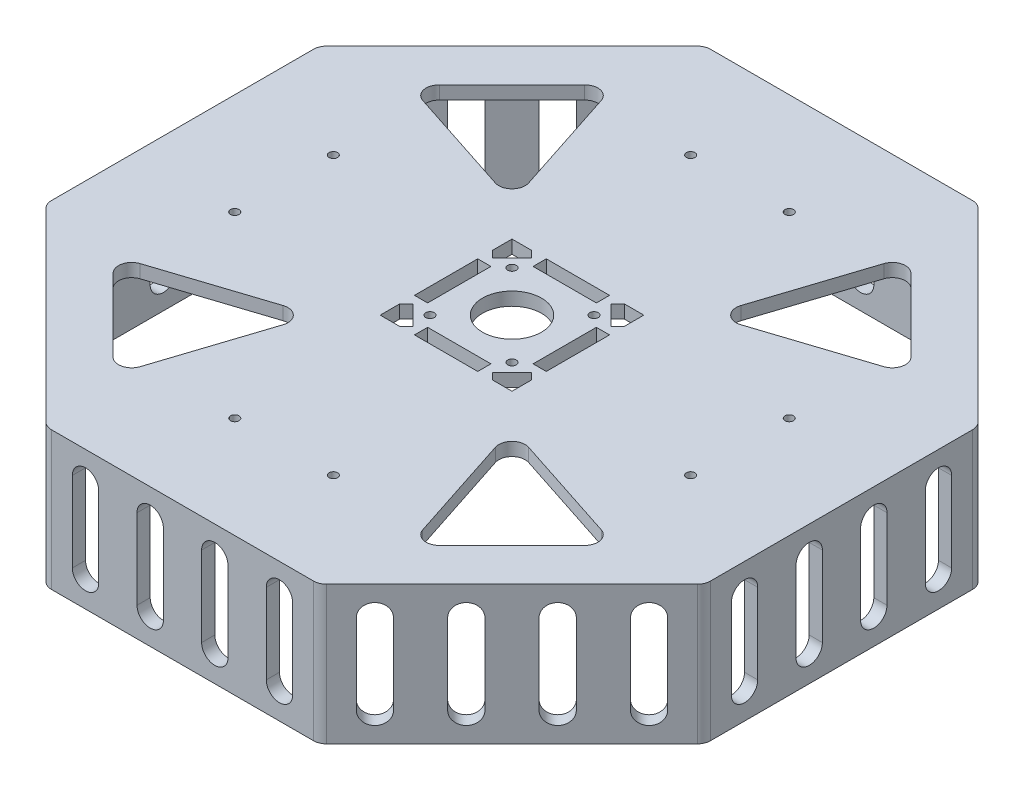
from build123d import *

# Parameters (mm, degrees)
SKETCH3_W           = 24
SKETCH3_H           = 5
SKETCH3_W_2         = 5
SKETCH3_H_2         = 24
SKETCH3_R           = 1.625
SKETCH3_R_2         = 11.2
BOSS_EXTRUDE3_DEPTH = 5
BOSS_EXTRUDE5_DEPTH = 47.48
CUT_EXTRUDE1_DEPTH  = 5
CIRPATTERN5_COUNT   = 8
FILLET2_R           = 5
CUT_EXTRUDE2_REACH  = 186.402
SKETCH7_R           = 1.625


with BuildPart() as part:
    # Sketch3 → Boss-Extrude3 (new body)
    with BuildSketch(Plane(origin=(0, 0, 0), x_dir=(1, 0, 0), z_dir=(0, 1, 0))):
        Polygon((51.776695297, 125), (-51.776695297, 125), (-125, 51.776695297), (-125, -51.776695297), (-51.776695297, -125), (51.776695297, -125), (125, -51.776695297), (125, 51.776695297), align=None)
        Polygon((-95.201010127, -56.119841047), (-37.207004987, -37.207004987), (-56.119841047, -95.201010127), align=None, mode=Mode.SUBTRACT)
        Polygon((56.119841047, -95.201010127), (37.207004987, -37.207004987), (95.201010127, -56.119841047), align=None, mode=Mode.SUBTRACT)
        Polygon((-17.646089476, -25), (-25, -25), (-25, -17.646089476), (-22.5, -15.146089476), (-15.146089476, -22.5), align=None, mode=Mode.SUBTRACT)
        with Locations((0, -22.5)):
            Rectangle(SKETCH3_W, SKETCH3_H, mode=Mode.SUBTRACT)
        Polygon((25, -25), (17.646089476, -25), (15.146089476, -22.5), (22.5, -15.146089476), (25, -17.646089476), align=None, mode=Mode.SUBTRACT)
        with Locations((22.5, 0)):
            Rectangle(SKETCH3_W_2, SKETCH3_H_2, mode=Mode.SUBTRACT)
        Polygon((25, 25), (25, 17.646089476), (22.5, 15.146089476), (15.146089476, 22.5), (17.646089476, 25), align=None, mode=Mode.SUBTRACT)
        with Locations((0, 22.5)):
            Rectangle(SKETCH3_W, SKETCH3_H, mode=Mode.SUBTRACT)
        Polygon((-25, 25), (-17.646089476, 25), (-15.146089476, 22.5), (-22.5, 15.146089476), (-25, 17.646089476), align=None, mode=Mode.SUBTRACT)
        with Locations((-22.5, 0)):
            Rectangle(SKETCH3_W_2, SKETCH3_H_2, mode=Mode.SUBTRACT)
        Polygon((-37.207004987, 37.207004987), (-95.201010127, 56.119841047), (-56.119841047, 95.201010127), align=None, mode=Mode.SUBTRACT)
        Polygon((95.201010127, 56.119841047), (37.207004987, 37.207004987), (56.119841047, 95.201010127), align=None, mode=Mode.SUBTRACT)
        with Locations((-15.55, -15.55)):
            Circle(SKETCH3_R, mode=Mode.SUBTRACT)
        with Locations((15.55, -15.55)):
            Circle(SKETCH3_R, mode=Mode.SUBTRACT)
        Circle(SKETCH3_R_2, mode=Mode.SUBTRACT)
        with Locations((-15.55, 15.55)):
            Circle(SKETCH3_R, mode=Mode.SUBTRACT)
        with Locations((15.55, 15.55)):
            Circle(SKETCH3_R, mode=Mode.SUBTRACT)
    extrude(amount=BOSS_EXTRUDE3_DEPTH)

    # Sketch5 → Boss-Extrude5 (add)
    with BuildSketch(Plane.XZ):
        Polygon((51.776695297, 125), (-51.776695297, 125), (-125, 51.776695297), (-125, -51.776695297), (-51.776695297, -125), (51.776695297, -125), (125, -51.776695297), (125, 51.776695297), align=None)
        Polygon((-49.705627485, 120), (-120, 49.705627485), (-120, -49.705627485), (-49.705627485, -120), (49.705627485, -120), (120, -49.705627485), (120, 49.705627485), (49.705627485, 120), align=None, mode=Mode.SUBTRACT)
    extrude(amount=BOSS_EXTRUDE5_DEPTH)

    # Sketch6 → Cut-Extrude1 (cut)
    with BuildSketch(Plane(origin=(-88.388347648, 0, 88.388347648), x_dir=(0.7071067811865478, 0, 0.7071067811865472), z_dir=(-0.7071067811865472, 0, 0.7071067811865478))):
        with BuildLine():
            Line((-31.776695297, -36.44), (-31.776695297, -6.04))
            ThreePointArc((-31.776695297, -6.04), (-36.776695297, -1.04), (-41.776695297, -6.04))
            Line((-41.776695297, -6.04), (-41.776695297, -36.44))
            ThreePointArc((-41.776695297, -36.44), (-36.776695297, -41.44), (-31.776695297, -36.44))
        make_face()
        with BuildLine():
            ThreePointArc((-7.258898432, -6.04), (-12.258898432, -1.04), (-17.258898432, -6.04))
            Line((-17.258898432, -6.04), (-17.258898432, -36.44))
            ThreePointArc((-17.258898432, -36.44), (-12.258898432, -41.44), (-7.258898432, -36.44))
            Line((-7.258898432, -36.44), (-7.258898432, -6.04))
        make_face()
        with BuildLine():
            ThreePointArc((17.258898432, -6.04), (12.258898432, -1.04), (7.258898432, -6.04))
            Line((7.258898432, -6.04), (7.258898432, -36.44))
            ThreePointArc((7.258898432, -36.44), (12.258898432, -41.44), (17.258898432, -36.44))
            Line((17.258898432, -36.44), (17.258898432, -6.04))
        make_face()
        with BuildLine():
            ThreePointArc((41.776695297, -6.04), (36.776695297, -1.04), (31.776695297, -6.04))
            Line((31.776695297, -6.04), (31.776695297, -36.44))
            ThreePointArc((31.776695297, -36.44), (36.776695297, -41.44), (41.776695297, -36.44))
            Line((41.776695297, -36.44), (41.776695297, -6.04))
        make_face()
    cut_extrude1 = extrude(amount=-CUT_EXTRUDE1_DEPTH, mode=Mode.SUBTRACT)

    # CirPattern5: Cut-Extrude1 ×8 about axis
    cirpattern5_axis = Axis((0, 5, 0), (0, 1, 0))
    for i in range(1, CIRPATTERN5_COUNT):
        add(cut_extrude1.rotate(cirpattern5_axis, i * 360 / CIRPATTERN5_COUNT), mode=Mode.SUBTRACT)

    # Fillet2
    fillet2_edges = [part.edges().sort_by_distance(p)[0] for p in [
        (-56.119841047, 2.5, 95.201010127),
        (-95.201010127, 2.5, 56.119841047),
        (-37.207004987, 2.5, 37.207004987),
        (56.119841047, 2.5, 95.201010127),
        (49.705627485, -23.74, 120),
        (95.201010127, 2.5, 56.119841047),
        (37.207004987, 2.5, 37.207004987),
        (37.207004987, 2.5, -37.207004987),
        (95.201010127, 2.5, -56.119841047),
        (56.119841047, 2.5, -95.201010127),
        (-95.201010127, 2.5, -56.119841047),
        (-37.207004987, 2.5, -37.207004987),
        (-56.119841047, 2.5, -95.201010127),
        (49.705627485, -23.74, -120),
        (51.776695297, -21.24, -125),
        (120, -23.74, 49.705627485),
        (120, -23.74, -49.705627485),
        (125, -21.24, -51.776695297),
        (125, -21.24, 51.776695297),
        (51.776695297, -21.24, 125),
        (-51.776695297, -21.24, 125),
        (-49.705627485, -23.74, 120),
        (-125, -21.24, 51.776695297),
        (-120, -23.74, 49.705627485),
        (-49.705627485, -23.74, -120),
        (-120, -23.74, -49.705627485),
        (-125, -21.24, -51.776695297),
        (-51.776695297, -21.24, -125),
    ]]
    fillet(fillet2_edges, radius=FILLET2_R)

    # Sketch7 → Cut-Extrude2 (cut, up to next)
    with BuildSketch(Plane(origin=(0, 5, 0), x_dir=(1, 0, 0), z_dir=(0, 1, 0)), mode=Mode.PRIVATE) as cut_extrude2_sk1:
        with Locations((-86.475, 18.7)):
            Circle(SKETCH7_R)
    cut_extrude2_tool1 = extrude(cut_extrude2_sk1.sketch, amount=-CUT_EXTRUDE2_REACH, mode=Mode.PRIVATE) & part.part
    # Sketch7 → Cut-Extrude2 (cut, up to next)
    with BuildSketch(Plane(origin=(0, 5, 0), x_dir=(1, 0, 0), z_dir=(0, 1, 0)), mode=Mode.PRIVATE) as cut_extrude2_sk2:
        with Locations((-86.475, -18.7)):
            Circle(SKETCH7_R)
    cut_extrude2_tool2 = extrude(cut_extrude2_sk2.sketch, amount=-CUT_EXTRUDE2_REACH, mode=Mode.PRIVATE) & part.part
    # Sketch7 → Cut-Extrude2 (cut, up to next)
    with BuildSketch(Plane(origin=(0, 5, 0), x_dir=(1, 0, 0), z_dir=(0, 1, 0)), mode=Mode.PRIVATE) as cut_extrude2_sk3:
        with Locations((18.7, 86.475)):
            Circle(SKETCH7_R)
    cut_extrude2_tool3 = extrude(cut_extrude2_sk3.sketch, amount=-CUT_EXTRUDE2_REACH, mode=Mode.PRIVATE) & part.part
    # Sketch7 → Cut-Extrude2 (cut, up to next)
    with BuildSketch(Plane(origin=(0, 5, 0), x_dir=(1, 0, 0), z_dir=(0, 1, 0)), mode=Mode.PRIVATE) as cut_extrude2_sk4:
        with Locations((-18.7, 86.475)):
            Circle(SKETCH7_R)
    cut_extrude2_tool4 = extrude(cut_extrude2_sk4.sketch, amount=-CUT_EXTRUDE2_REACH, mode=Mode.PRIVATE) & part.part
    # Sketch7 → Cut-Extrude2 (cut, up to next)
    with BuildSketch(Plane(origin=(0, 5, 0), x_dir=(1, 0, 0), z_dir=(0, 1, 0)), mode=Mode.PRIVATE) as cut_extrude2_sk5:
        with Locations((86.475, -18.7)):
            Circle(SKETCH7_R)
    cut_extrude2_tool5 = extrude(cut_extrude2_sk5.sketch, amount=-CUT_EXTRUDE2_REACH, mode=Mode.PRIVATE) & part.part
    # Sketch7 → Cut-Extrude2 (cut, up to next)
    with BuildSketch(Plane(origin=(0, 5, 0), x_dir=(1, 0, 0), z_dir=(0, 1, 0)), mode=Mode.PRIVATE) as cut_extrude2_sk6:
        with Locations((86.475, 18.7)):
            Circle(SKETCH7_R)
    cut_extrude2_tool6 = extrude(cut_extrude2_sk6.sketch, amount=-CUT_EXTRUDE2_REACH, mode=Mode.PRIVATE) & part.part
    # Sketch7 → Cut-Extrude2 (cut, up to next)
    with BuildSketch(Plane(origin=(0, 5, 0), x_dir=(1, 0, 0), z_dir=(0, 1, 0)), mode=Mode.PRIVATE) as cut_extrude2_sk7:
        with Locations((-18.7, -86.475)):
            Circle(SKETCH7_R)
    cut_extrude2_tool7 = extrude(cut_extrude2_sk7.sketch, amount=-CUT_EXTRUDE2_REACH, mode=Mode.PRIVATE) & part.part
    # Sketch7 → Cut-Extrude2 (cut, up to next)
    with BuildSketch(Plane(origin=(0, 5, 0), x_dir=(1, 0, 0), z_dir=(0, 1, 0)), mode=Mode.PRIVATE) as cut_extrude2_sk8:
        with Locations((18.7, -86.475)):
            Circle(SKETCH7_R)
    cut_extrude2_tool8 = extrude(cut_extrude2_sk8.sketch, amount=-CUT_EXTRUDE2_REACH, mode=Mode.PRIVATE) & part.part
    add(cut_extrude2_tool1.solids().sort_by_distance((-86.475, 5, -18.7))[0], mode=Mode.SUBTRACT)
    add(cut_extrude2_tool2.solids().sort_by_distance((-86.475, 5, 18.7))[0], mode=Mode.SUBTRACT)
    add(cut_extrude2_tool3.solids().sort_by_distance((18.7, 5, -86.475))[0], mode=Mode.SUBTRACT)
    add(cut_extrude2_tool4.solids().sort_by_distance((-18.7, 5, -86.475))[0], mode=Mode.SUBTRACT)
    add(cut_extrude2_tool5.solids().sort_by_distance((86.475, 5, 18.7))[0], mode=Mode.SUBTRACT)
    add(cut_extrude2_tool6.solids().sort_by_distance((86.475, 5, -18.7))[0], mode=Mode.SUBTRACT)
    add(cut_extrude2_tool7.solids().sort_by_distance((-18.7, 5, 86.475))[0], mode=Mode.SUBTRACT)
    add(cut_extrude2_tool8.solids().sort_by_distance((18.7, 5, 86.475))[0], mode=Mode.SUBTRACT)


solid = part.part
